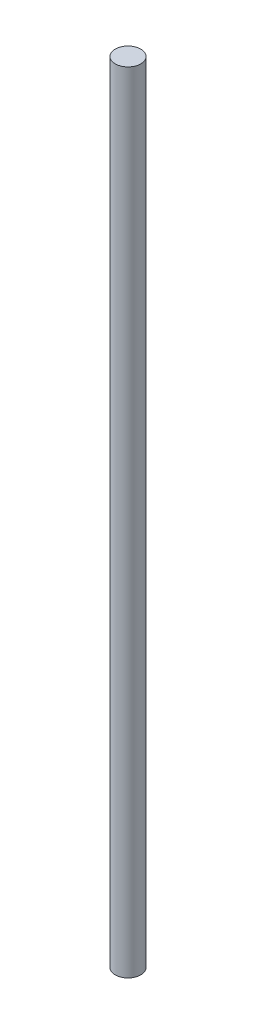
from build123d import *

# Parameters (mm, degrees)
ESQUISSE1_R        = 1.5
BOSS_EXTRU_1_DEPTH = 92.4


with BuildPart() as part:
    # Esquisse1 → Boss.-Extru.1 (new body)
    with BuildSketch(Plane(origin=(0, 0, 0), x_dir=(1, 0, 0), z_dir=(0, 1, 0))):
        Circle(ESQUISSE1_R)
    extrude(amount=BOSS_EXTRU_1_DEPTH)


solid = part.part
